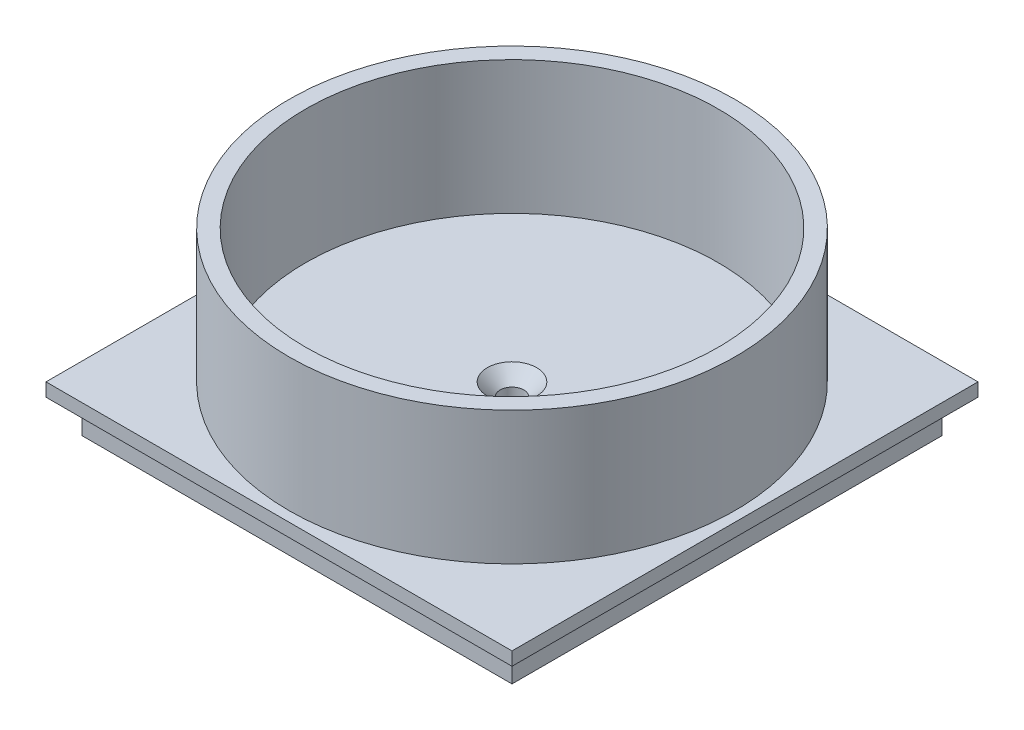
from build123d import *

# Parameters (mm, degrees)
SKETCH1_W                                       = 82.042
SKETCH1_H                                       = 82.042
BOSS_EXTRUDE1_DEPTH                             = 6.35
SKETCH3_W                                       = 88.9
SKETCH3_H                                       = 88.9
BOSS_EXTRUDE3_DEPTH                             = 2.54
SKETCH4_R                                       = 2.25
CUT_EXTRUDE1_DEPTH                              = 9.89
SKETCH5_R                                       = 42.545
SKETCH5_R_2                                     = 39.37
BOSS_EXTRUDE4_DEPTH                             = 25.4
CSK_FOR_M4_FLAT_HEAD_MACHINE_SCREW1_D           = 4.5
CSK_FOR_M4_FLAT_HEAD_MACHINE_SCREW1_DEPTH       = 3.99999
CSK_FOR_M4_FLAT_HEAD_MACHINE_SCREW1_CSINK_D     = 9.4
CSK_FOR_M4_FLAT_HEAD_MACHINE_SCREW1_CSINK_ANGLE = 90
CSK_FOR_M4_FLAT_HEAD_MACHINE_SCREW1_TIP         = 1.351936393


with BuildPart() as part:
    # Sketch1 → Boss-Extrude1 (new body)
    with BuildSketch(Plane(origin=(0, 0, 0), x_dir=(1, 0, 0), z_dir=(0, 1, 0))):
        with Locations((41.021, 41.021)):
            Rectangle(SKETCH1_W, SKETCH1_H)
    extrude(amount=BOSS_EXTRUDE1_DEPTH)

    # Sketch3 → Boss-Extrude3 (add)
    with BuildSketch(Plane(origin=(0, 6.35, 0), x_dir=(1, 0, 0), z_dir=(0, 1, 0))):
        with Locations((41.021, 41.021)):
            Rectangle(SKETCH3_W, SKETCH3_H)
    extrude(amount=BOSS_EXTRUDE3_DEPTH)

    # Sketch4 → Cut-Extrude1 (cut, through all)
    with BuildSketch(Plane(origin=(0, 8.89, 0), x_dir=(1, 0, 0), z_dir=(0, 1, 0))):
        with Locations((41.021, 41.021)):
            Circle(SKETCH4_R)
    extrude(amount=-CUT_EXTRUDE1_DEPTH, mode=Mode.SUBTRACT)

    # Sketch5 → Boss-Extrude4 (add)
    with BuildSketch(Plane(origin=(0, 8.89, 0), x_dir=(1, 0, 0), z_dir=(0, 1, 0))):
        with Locations((41.021, 41.021)):
            Circle(SKETCH5_R)
        with Locations((41.021, 41.021)):
            Circle(SKETCH5_R_2, mode=Mode.SUBTRACT)
    extrude(amount=BOSS_EXTRUDE4_DEPTH)

    # CSK for M4 Flat Head Machine Screw1
    with Locations(Plane(origin=(0, 8.89, 0), x_dir=(1, 0, 0), z_dir=(0, 1, 0))):
        with Locations((41.021, 41.021)):
            CounterSinkHole(CSK_FOR_M4_FLAT_HEAD_MACHINE_SCREW1_D / 2, CSK_FOR_M4_FLAT_HEAD_MACHINE_SCREW1_CSINK_D / 2, depth=CSK_FOR_M4_FLAT_HEAD_MACHINE_SCREW1_DEPTH, counter_sink_angle=CSK_FOR_M4_FLAT_HEAD_MACHINE_SCREW1_CSINK_ANGLE)
            with Locations((0, 0, -(CSK_FOR_M4_FLAT_HEAD_MACHINE_SCREW1_DEPTH + CSK_FOR_M4_FLAT_HEAD_MACHINE_SCREW1_TIP / 2))):  # 118° drill point
                Cone(0, CSK_FOR_M4_FLAT_HEAD_MACHINE_SCREW1_D / 2, CSK_FOR_M4_FLAT_HEAD_MACHINE_SCREW1_TIP, mode=Mode.SUBTRACT)


solid = part.part
